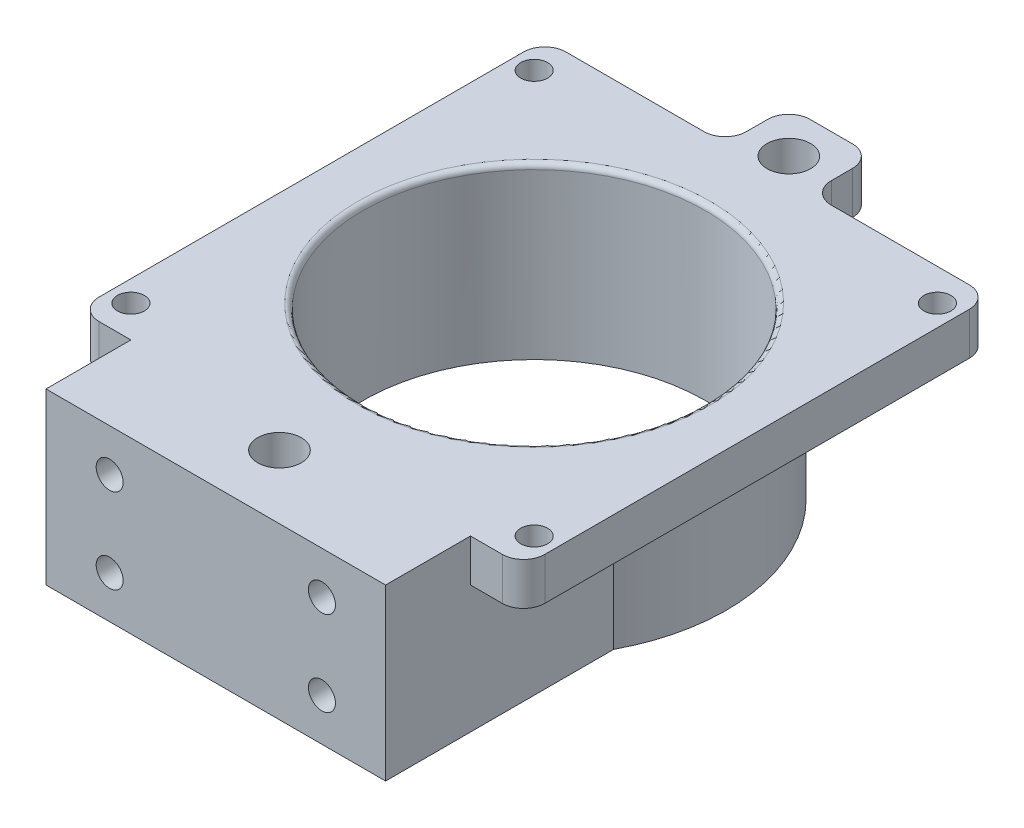
from build123d import *

# Parameters (mm, degrees)
SKETCH1_R                  = 28.7655
BOSS_EXTRUDE1_DEPTH        = 19.05
BOSS_EXTRUDE2_DEPTH        = 6.35
FILLET1_R                  = 3.175
SKETCH8_W                  = 50.8
SKETCH8_H                  = 25.4
BOSS_EXTRUDE4_DEPTH        = 38.1
SKETCH5_R                  = 25.5905
CUT_EXTRUDE1_DEPTH         = 26.4
FILLET2_R                  = 0.79375
F_10_32_TAPPED_HOLE1_D     = 4.0386
F_10_32_TAPPED_HOLE1_DEPTH = 6.35
F_0_257_DIAMETER_HOLE1_D   = 6.5278
F_10_32_TAPPED_HOLE2_D     = 4.0386
F_10_32_TAPPED_HOLE2_DEPTH = 16.764
F_10_32_TAPPED_HOLE2_TIP   = 1.213317848


with BuildPart() as part:
    # Sketch1 → Boss-Extrude1 (new body)
    with BuildSketch(Plane(origin=(0, 0, 0), x_dir=(1, 0, 0), z_dir=(0, 1, 0))):
        Circle(SKETCH1_R)
    extrude(amount=BOSS_EXTRUDE1_DEPTH)



with BuildPart() as body_2:
    # Sketch4 → Boss-Extrude2 (new body)
    with BuildSketch(Plane(origin=(0, 19.05, 0), x_dir=(1, 0, 0), z_dir=(0, 1, 0))):
        Polygon((-33.3375, 34.925), (-6.35, 34.925), (-6.35, 44.45), (6.35, 44.45), (6.35, 34.925), (33.3375, 34.925), (33.3375, -34.925), (-33.3375, -34.925), align=None)
    extrude(amount=BOSS_EXTRUDE2_DEPTH)

    # Fillet1
    fillet1_edges = [body_2.edges().sort_by_distance(p)[0] for p in [
        (33.3375, 22.225, 34.925),
        (-33.3375, 22.225, 34.925),
        (-33.3375, 22.225, -34.925),
        (-6.35, 22.225, -34.925),
        (-6.35, 22.225, -44.45),
        (6.35, 22.225, -44.45),
        (6.35, 22.225, -34.925),
        (33.3375, 22.225, -34.925),
    ]]
    fillet(fillet1_edges, radius=FILLET1_R)


with BuildPart() as part_1:
    add(part.part)

    add(body_2.part)  # Boss-Extrude4 merges body 2
    # Sketch8 → Boss-Extrude4 (add)
    with BuildSketch(Plane.XY.offset(47.625)):
        with Locations((0, 12.7)):
            Rectangle(SKETCH8_W, SKETCH8_H)
    extrude(amount=-BOSS_EXTRUDE4_DEPTH)

    # Sketch5 → Cut-Extrude1 (cut, through all)
    with BuildSketch(Plane(origin=(0, 25.4, 0), x_dir=(1, 0, 0), z_dir=(0, 1, 0))):
        Circle(SKETCH5_R)
    extrude(amount=-CUT_EXTRUDE1_DEPTH, mode=Mode.SUBTRACT)

    # Fillet2
    fillet2_edges = [part_1.edges().sort_by_distance(p)[0] for p in [
        (-25.5905, 25.4, 0),
    ]]
    fillet(fillet2_edges, radius=FILLET2_R)

    # #10-32 Tapped Hole1
    with Locations(Plane(origin=(0, 25.4, 0), x_dir=(1, 0, 0), z_dir=(0, 1, 0))):
        with Locations((-30.1625, 30.1625), (30.1625, 30.1625), (30.1625, -30.1625), (-30.1625, -30.1625)):
            Hole(F_10_32_TAPPED_HOLE1_D / 2, depth=F_10_32_TAPPED_HOLE1_DEPTH)

    # F (0.257) Diameter Hole1 (through all)
    with Locations(Plane(origin=(0, 25.4, 0), x_dir=(1, 0, 0), z_dir=(0, 1, 0))):
        with Locations((0, 38.1), (0, -38.1)):
            Hole(F_0_257_DIAMETER_HOLE1_D / 2)

    # #10-32 Tapped Hole2
    with Locations(Plane.XY.offset(47.625)):
        with Locations((-15.875, 19.05), (-15.875, 6.35), (15.875, 6.35), (15.875, 19.05)):
            Hole(F_10_32_TAPPED_HOLE2_D / 2, depth=F_10_32_TAPPED_HOLE2_DEPTH)
            with Locations((0, 0, -(F_10_32_TAPPED_HOLE2_DEPTH + F_10_32_TAPPED_HOLE2_TIP / 2))):  # 118° drill point
                Cone(0, F_10_32_TAPPED_HOLE2_D / 2, F_10_32_TAPPED_HOLE2_TIP, mode=Mode.SUBTRACT)


solid = part_1.part
